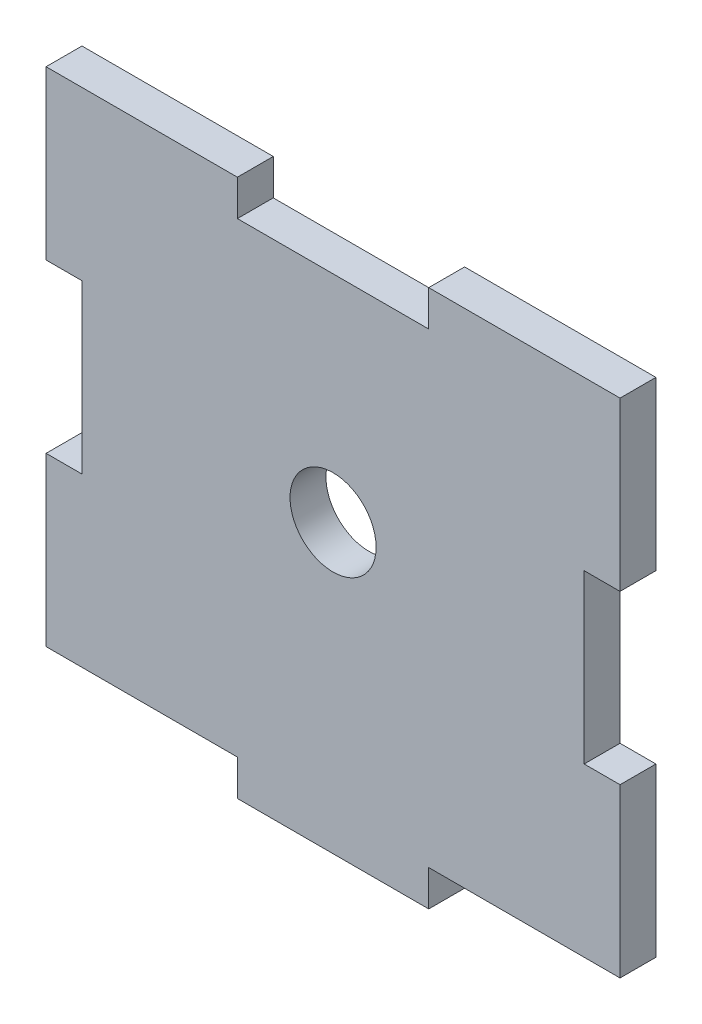
from build123d import *

# Parameters (mm, degrees)
SALIENTE_EXTRUIR1_DEPTH = 5
CROQUIS2_W              = 26.666666666
CROQUIS2_H              = 5
CORTAR_EXTRUIR1_DEPTH   = 10
CORTAR_EXTRUIR3_DEPTH   = 10


with BuildPart() as part:
    # Croquis1 → Saliente-Extruir1 (new body)
    with BuildSketch(Plane.XY):
        Polygon((0, 28.333333333), (0, 5), (26.666666667, 5), (26.666666667, 0), (53.333333333, 0), (53.333333333, 5), (80, 5), (80, 28.333333333), (75, 28.333333333), (75, 51.666666667), (80, 51.666666667), (80, 75), (0, 75), (0, 51.666666667), (5, 51.666666667), (5, 28.333333333), align=None)
    extrude(amount=SALIENTE_EXTRUIR1_DEPTH)

    # Croquis2 → Cortar-Extruir1 (cut)
    with BuildSketch(Plane.XY.offset(5)):
        with Locations((40, 72.5)):
            Rectangle(CROQUIS2_W, CROQUIS2_H)
    extrude(amount=-CORTAR_EXTRUIR1_DEPTH, mode=Mode.SUBTRACT)

    # Croquis5 → Cortar-Extruir3 (cut)
    with BuildSketch(Plane.XY.offset(5)):
        with BuildLine():
            ThreePointArc((46, 40), (44.242640687, 44.242640687), (40, 46))
            Line((40, 46), (40, 40))
            Line((40, 40), (46, 40))
        make_face()
        with BuildLine():
            Line((40, 40), (40, 46))
            ThreePointArc((40, 46), (35.757359313, 35.757359313), (46, 40))
            Line((46, 40), (40, 40))
        make_face()
    extrude(amount=-CORTAR_EXTRUIR3_DEPTH, mode=Mode.SUBTRACT)


solid = part.part
